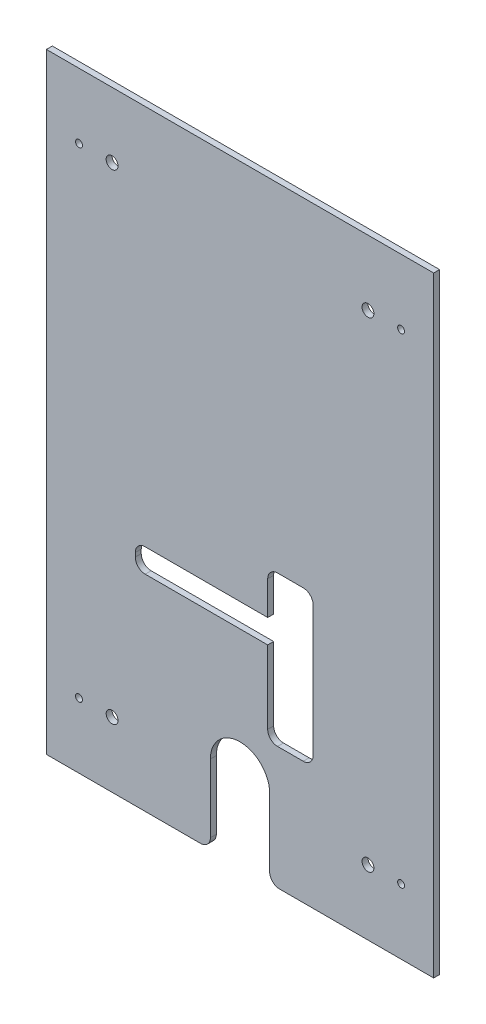
from build123d import *

# Parameters (mm, degrees)
ESQUISSE1_W             = 196
ESQUISSE1_H             = 309
ESQUISSE1_R             = 1.75
ESQUISSE1_R_2           = 3
BOSS_EXTRU_1_DEPTH      = 3
ENL_V_MAT_EXTRU_1_REACH = 5
CONG_1_R                = 5
ENL_V_MAT_EXTRU_2_DEPTH = 4
CONG_2_R                = 5


with BuildPart() as part:
    # Esquisse1 → Boss.-Extru.1 (new body)
    with BuildSketch(Plane.XY):
        Rectangle(ESQUISSE1_W, ESQUISSE1_H)
        with Locations((-81.5, 121.5)):
            Circle(ESQUISSE1_R, mode=Mode.SUBTRACT)
        with Locations((81.5, 121.5)):
            Circle(ESQUISSE1_R, mode=Mode.SUBTRACT)
        with Locations((81.5, -121.5)):
            Circle(ESQUISSE1_R, mode=Mode.SUBTRACT)
        with Locations((-81.5, -121.5)):
            Circle(ESQUISSE1_R, mode=Mode.SUBTRACT)
        with Locations((64.75, 121.5)):
            Circle(ESQUISSE1_R_2, mode=Mode.SUBTRACT)
        with Locations((-64.75, 121.5)):
            Circle(ESQUISSE1_R_2, mode=Mode.SUBTRACT)
        with Locations((-64.75, -121.5)):
            Circle(ESQUISSE1_R_2, mode=Mode.SUBTRACT)
        with Locations((64.75, -121.5)):
            Circle(ESQUISSE1_R_2, mode=Mode.SUBTRACT)
    extrude(amount=BOSS_EXTRU_1_DEPTH)

    # Esquisse2 → Enlèv. mat.-Extru.1 (cut, up to next)
    with BuildSketch(Plane.XY.offset(3), mode=Mode.PRIVATE) as enl_v_mat_extru_1_sk1:
        with BuildLine():
            Line((-15, -154.5), (-15, -115))
            ThreePointArc((-15, -115), (0, -100), (15, -115))
            Line((15, -115), (15, -154.5))
            ThreePointArc((15, -154.5), (0, -169.5), (-15, -154.5))
        make_face()
    enl_v_mat_extru_1_tool1 = extrude(enl_v_mat_extru_1_sk1.sketch, amount=-ENL_V_MAT_EXTRU_1_REACH, mode=Mode.PRIVATE) & part.part
    add(enl_v_mat_extru_1_tool1.solids().sort_by_distance((0, -134.75, 3))[0], mode=Mode.SUBTRACT)

    # Congé1
    cong_1_edges = [part.edges().sort_by_distance(p)[0] for p in [
        (-15, -154.5, 1.5),
        (15, -154.5, 1.5),
    ]]
    fillet(cong_1_edges, radius=CONG_1_R)

    # Esquisse3 → Enlèv. mat.-Extru.2 (cut, through all)
    with BuildSketch(Plane.XY.offset(3)):
        Polygon((-53, -38.5), (14, -38.5), (14, -16.5), (37, -16.5), (37, -92.5), (14, -92.5), (14, -50.5), (-53, -50.5), align=None)
    extrude(amount=-ENL_V_MAT_EXTRU_2_DEPTH, mode=Mode.SUBTRACT)

    # Congé2
    cong_2_edges = [part.edges().sort_by_distance(p)[0] for p in [
        (-53, -50.5, 1.5),
        (-53, -38.5, 1.5),
        (14, -16.5, 1.5),
        (37, -16.5, 1.5),
        (37, -92.5, 1.5),
        (14, -92.5, 1.5),
    ]]
    fillet(cong_2_edges, radius=CONG_2_R)


solid = part.part
